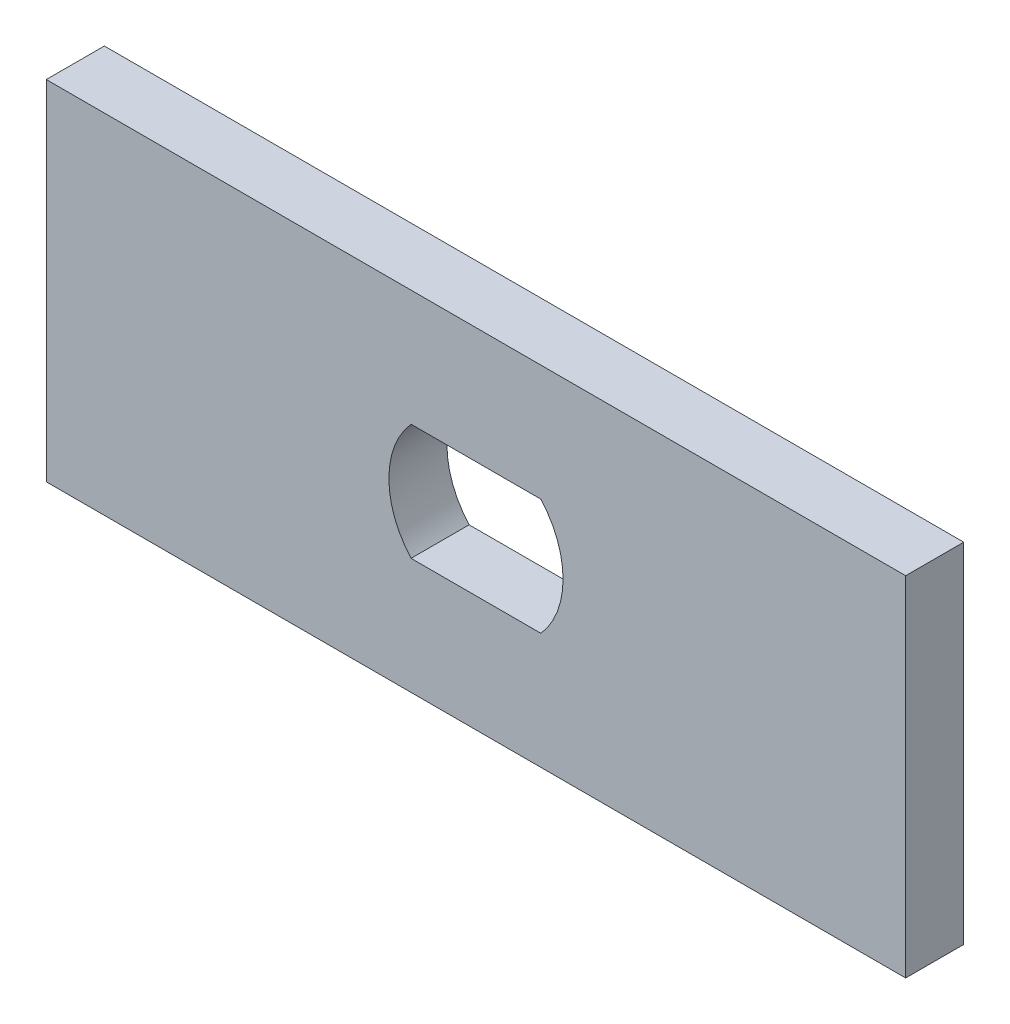
from build123d import *

# Parameters (mm, degrees)
SKETCH1_W           = 93.98
SKETCH1_H           = 38.1
BOSS_EXTRUDE1_DEPTH = 6.35


with BuildPart() as part:
    # Sketch1 → Boss-Extrude1 (new body)
    with BuildSketch(Plane.XY):
        Rectangle(SKETCH1_W, SKETCH1_H)
        with BuildLine():
            Line((-7.099515829, -6.35), (7.099515829, -6.35))
            ThreePointArc((7.099515829, -6.35), (9.525, 0), (7.099515829, 6.35))
            Line((7.099515829, 6.35), (-7.099515829, 6.35))
            ThreePointArc((-7.099515829, 6.35), (-9.525, 0), (-7.099515829, -6.35))
        make_face(mode=Mode.SUBTRACT)
    extrude(amount=BOSS_EXTRUDE1_DEPTH)


solid = part.part
